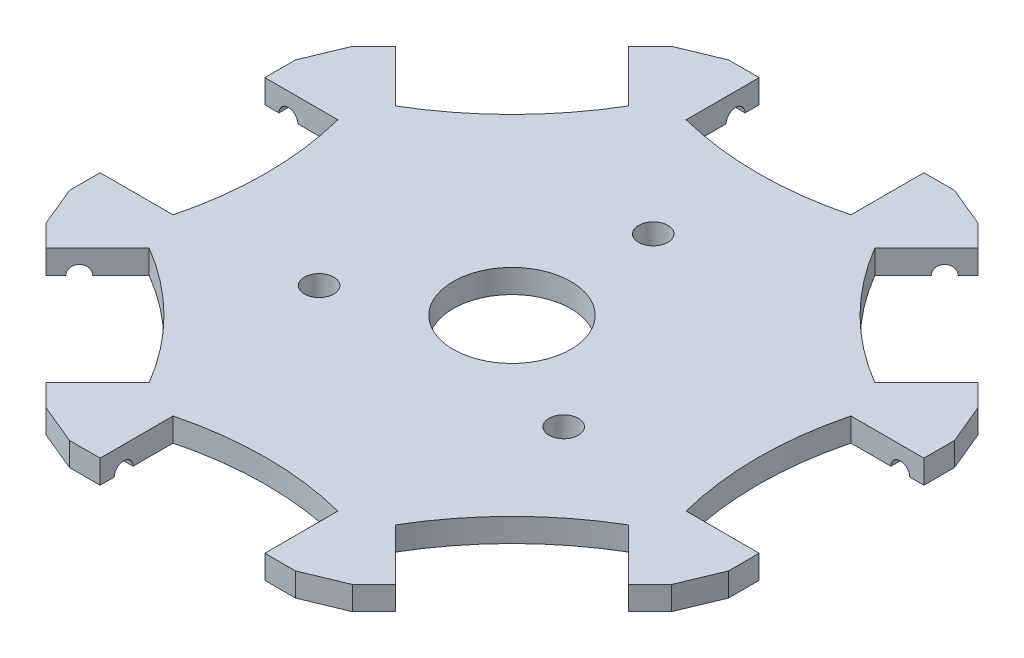
from build123d import *

# Parameters (mm, degrees)
SKETCH2_R                 = 5
BOSS_EXTRUDE2_DEPTH       = 2
SKETCH3_R                 = 0.8
CUT_EXTRUDE1_DEPTH        = 2
SKETCH4_R                 = 0.8
CUT_EXTRUDE2_DEPTH        = 2
CHAMFER1_SIZE             = 2
CIRPATTERN3_COUNT         = 8
F_2_5MM_DOWEL_HOLE1_D     = 2.5
F_2_5MM_DOWEL_HOLE1_DEPTH = 10
F_2_5MM_DOWEL_HOLE1_TIP   = 0.751075774


with BuildPart() as part:
    # Sketch2 → Boss-Extrude2 (new body)
    with BuildSketch(Plane(origin=(0, 0, 0), x_dir=(1, 0, 0), z_dir=(0, 1, 0))):
        with BuildLine():
            Line((-7, 21.800048896), (-7, 28.000048896))
            Line((-7, 28.000048896), (-11.598, 28.000048896))
            Line((-11.598, 28.000048896), (-14.84927698, 24.748771917))
            Line((-14.84927698, 24.748771917), (-10.465214937, 20.364709873))
            ThreePointArc((-10.465214937, 20.364709873), (-14.786262044, 14.786262044), (-20.364709873, 10.465214937))
            Line((-20.364709873, 10.465214937), (-24.748771917, 14.84927698))
            Line((-24.748771917, 14.84927698), (-28.000048896, 11.598))
            Line((-28.000048896, 11.598), (-28.000048896, 7))
            Line((-28.000048896, 7), (-21.800048896, 7))
            ThreePointArc((-21.800048896, 7), (-20.91093232, 0), (-21.800048896, -7))
            Line((-21.800048896, -7), (-28.000048896, -7))
            Line((-28.000048896, -7), (-28.000048896, -11.598))
            Line((-28.000048896, -11.598), (-24.748771917, -14.84927698))
            Line((-24.748771917, -14.84927698), (-20.364709873, -10.465214937))
            ThreePointArc((-20.364709873, -10.465214937), (-14.786262044, -14.786262044), (-10.465214937, -20.364709873))
            Line((-10.465214937, -20.364709873), (-14.84927698, -24.748771917))
            Line((-14.84927698, -24.748771917), (-11.598, -28.000048896))
            Line((-11.598, -28.000048896), (-7, -28.000048896))
            Line((-7, -28.000048896), (-7, -21.800048896))
            ThreePointArc((-7, -21.800048896), (0, -20.91093232), (7, -21.800048896))
            Line((7, -21.800048896), (7, -28.000048896))
            Line((7, -28.000048896), (11.598, -28.000048896))
            Line((11.598, -28.000048896), (14.84927698, -24.748771917))
            Line((14.84927698, -24.748771917), (10.465214937, -20.364709873))
            ThreePointArc((10.465214937, -20.364709873), (14.786262044, -14.786262044), (20.364709873, -10.465214937))
            Line((20.364709873, -10.465214937), (24.748771917, -14.84927698))
            Line((24.748771917, -14.84927698), (28.000048896, -11.598))
            Line((28.000048896, -11.598), (28.000048896, -7))
            Line((28.000048896, -7), (21.800048896, -7))
            ThreePointArc((21.800048896, -7), (20.91093232, 0), (21.800048896, 7))
            Line((21.800048896, 7), (28.000048896, 7))
            Line((28.000048896, 7), (28.000048896, 11.598))
            Line((28.000048896, 11.598), (24.748771917, 14.84927698))
            Line((24.748771917, 14.84927698), (20.364709873, 10.465214937))
            ThreePointArc((20.364709873, 10.465214937), (14.786262044, 14.786262044), (10.465214937, 20.364709873))
            Line((10.465214937, 20.364709873), (14.84927698, 24.748771917))
            Line((14.84927698, 24.748771917), (11.598, 28.000048896))
            Line((11.598, 28.000048896), (7, 28.000048896))
            Line((7, 28.000048896), (7, 21.800048896))
            ThreePointArc((7, 21.800048896), (0, 20.91093232), (-7, 21.800048896))
        make_face()
        Circle(SKETCH2_R, mode=Mode.SUBTRACT)
    extrude(amount=BOSS_EXTRUDE2_DEPTH)

    # Sketch3 → Cut-Extrude1 (cut)
    with BuildSketch(Plane.ZY.offset(-7)):
        with Locations((-26.000048896, 0)):
            Circle(SKETCH3_R)
    cut_extrude1 = extrude(amount=-CUT_EXTRUDE1_DEPTH, mode=Mode.SUBTRACT)

    # Sketch4 → Cut-Extrude2 (cut)
    with BuildSketch(Plane(origin=(-7, 0, 0), x_dir=(0, 0, -1), z_dir=(1, 0, 0))):
        with Locations((26.000048896, 0)):
            Circle(SKETCH4_R)
    cut_extrude2 = extrude(amount=-CUT_EXTRUDE2_DEPTH, mode=Mode.SUBTRACT)

    # Chamfer1
    chamfer1_edges = [part.edges().sort_by_distance(p)[0] for p in [
        (-11.598, 1, -28.000048896),
        (11.598, 1, -28.000048896),
        (28.000048896, 1, -11.598),
        (28.000048896, 1, 11.598),
        (11.598, 1, 28.000048896),
        (-11.598, 1, 28.000048896),
        (-28.000048896, 1, 11.598),
        (-28.000048896, 1, -11.598),
    ]]
    chamfer(chamfer1_edges, length=CHAMFER1_SIZE)

    # CirPattern3: Cut-Extrude1, Cut-Extrude2 ×8 about axis
    cirpattern3_axis = Axis((0, 0, 0), (0, 1, 0))
    for i in range(1, CIRPATTERN3_COUNT):
        add(cut_extrude1.rotate(cirpattern3_axis, i * 360 / CIRPATTERN3_COUNT), mode=Mode.SUBTRACT)
        add(cut_extrude2.rotate(cirpattern3_axis, i * 360 / CIRPATTERN3_COUNT), mode=Mode.SUBTRACT)

    # Ø2.5mm Dowel Hole1
    with Locations(Plane(origin=(0, 2, 0), x_dir=(1, 0, 0), z_dir=(0, 1, 0))):
        with Locations((0, 12), (10.392304845, -6), (-10.392304845, -6), (0, 0)):
            Hole(F_2_5MM_DOWEL_HOLE1_D / 2, depth=F_2_5MM_DOWEL_HOLE1_DEPTH)
            with Locations((0, 0, -(F_2_5MM_DOWEL_HOLE1_DEPTH + F_2_5MM_DOWEL_HOLE1_TIP / 2))):  # 118° drill point
                Cone(0, F_2_5MM_DOWEL_HOLE1_D / 2, F_2_5MM_DOWEL_HOLE1_TIP, mode=Mode.SUBTRACT)


solid = part.part
